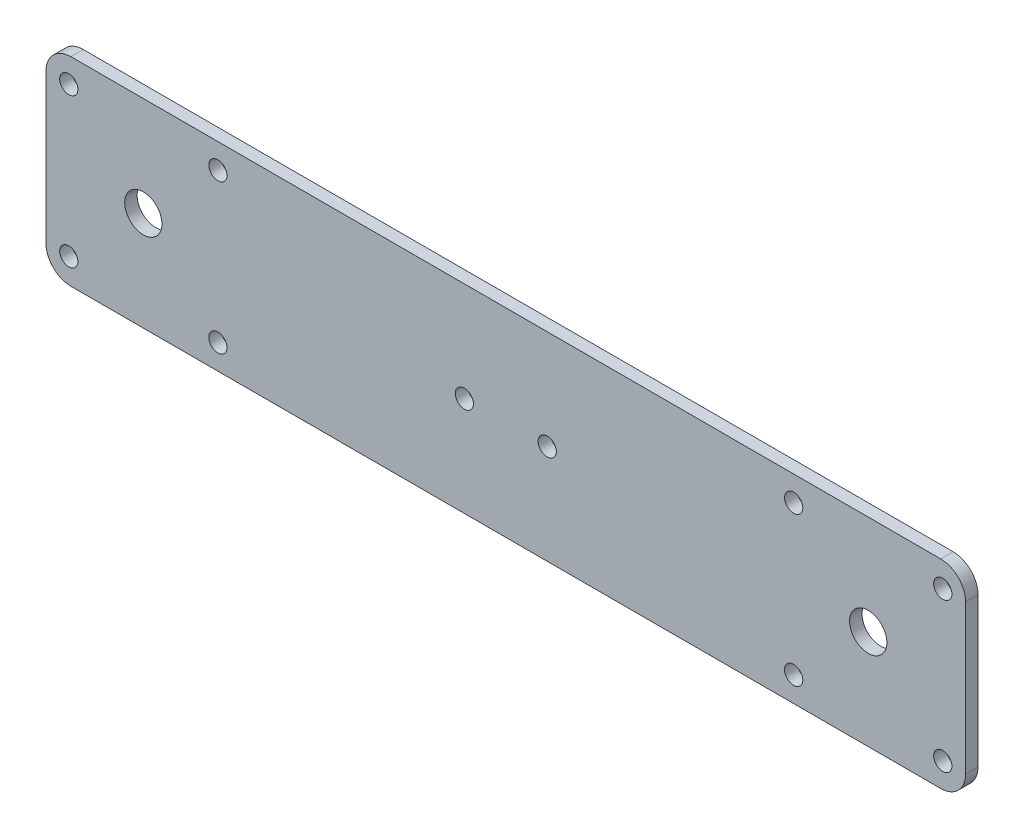
from build123d import *

# Parameters (mm, degrees)
ESQUISSE1_W             = 366
ESQUISSE1_H             = 166
ESQUISSE1_R             = 2.2
ESQUISSE1_R_2           = 4.5
ESQUISSE1_R_3           = 6.5
BOSS_EXTRU_1_DEPTH      = 3
ESQUISSE2_OUTSIDE_W     = 448.38
ESQUISSE2_OUTSIDE_H     = 248.38
ESQUISSE2_OUTSIDE_W_2   = 222
ESQUISSE2_OUTSIDE_H_2   = 48
ENL_V_MAT_EXTRU_1_DEPTH = 4
CONG_1_R                = 6


with BuildPart() as part:
    # Esquisse1 → Boss.-Extru.1 (new body)
    with BuildSketch(Plane.XY):
        with Locations((183, 83)):
            Rectangle(ESQUISSE1_W, ESQUISSE1_H)
        with Locations((13, 153)):
            Circle(ESQUISSE1_R, mode=Mode.SUBTRACT)
        with Locations((13, 13)):
            Circle(ESQUISSE1_R, mode=Mode.SUBTRACT)
        with Locations((13, 83)):
            Circle(ESQUISSE1_R, mode=Mode.SUBTRACT)
        with Locations((173, 153)):
            Circle(ESQUISSE1_R, mode=Mode.SUBTRACT)
        with Locations((193, 83)):
            Circle(ESQUISSE1_R, mode=Mode.SUBTRACT)
        with Locations((173, 83)):
            Circle(ESQUISSE1_R, mode=Mode.SUBTRACT)
        with Locations((193, 153)):
            Circle(ESQUISSE1_R, mode=Mode.SUBTRACT)
        with Locations((353, 83)):
            Circle(ESQUISSE1_R, mode=Mode.SUBTRACT)
        with Locations((353, 13)):
            Circle(ESQUISSE1_R, mode=Mode.SUBTRACT)
        with Locations((353, 153)):
            Circle(ESQUISSE1_R, mode=Mode.SUBTRACT)
        with Locations((193, 13)):
            Circle(ESQUISSE1_R, mode=Mode.SUBTRACT)
        with Locations((173, 13)):
            Circle(ESQUISSE1_R, mode=Mode.SUBTRACT)
        with Locations((270.5, 83)):
            Circle(ESQUISSE1_R_2, mode=Mode.SUBTRACT)
        with Locations((95.5, 83)):
            Circle(ESQUISSE1_R_2, mode=Mode.SUBTRACT)
        with Locations((77.5, 101)):
            Circle(ESQUISSE1_R, mode=Mode.SUBTRACT)
        with Locations((113.5, 101)):
            Circle(ESQUISSE1_R, mode=Mode.SUBTRACT)
        with Locations((77.5, 65)):
            Circle(ESQUISSE1_R, mode=Mode.SUBTRACT)
        with Locations((113.5, 65)):
            Circle(ESQUISSE1_R, mode=Mode.SUBTRACT)
        with Locations((288.5, 65)):
            Circle(ESQUISSE1_R, mode=Mode.SUBTRACT)
        with Locations((252.5, 65)):
            Circle(ESQUISSE1_R, mode=Mode.SUBTRACT)
        with Locations((252.5, 101)):
            Circle(ESQUISSE1_R, mode=Mode.SUBTRACT)
        with Locations((288.5, 101)):
            Circle(ESQUISSE1_R, mode=Mode.SUBTRACT)
        with Locations((37, 49)):
            Circle(ESQUISSE1_R_3, mode=Mode.SUBTRACT)
        with Locations((61, 49)):
            Circle(ESQUISSE1_R_3, mode=Mode.SUBTRACT)
        with Locations((85, 49)):
            Circle(ESQUISSE1_R, mode=Mode.SUBTRACT)
        with Locations((13, 49)):
            Circle(ESQUISSE1_R, mode=Mode.SUBTRACT)
    extrude(amount=BOSS_EXTRU_1_DEPTH)

    # Esquisse2 outside → Enlèv. mat.-Extru.1 (cut, through all)
    with BuildSketch(Plane.XY.offset(3)):
        with Locations((183, 83)):
            Rectangle(ESQUISSE2_OUTSIDE_W, ESQUISSE2_OUTSIDE_H)
        with Locations((183, 83)):
            Rectangle(ESQUISSE2_OUTSIDE_W_2, ESQUISSE2_OUTSIDE_H_2, mode=Mode.SUBTRACT)
    extrude(amount=-ENL_V_MAT_EXTRU_1_DEPTH, mode=Mode.SUBTRACT)

    # Congé1
    cong_1_edges = [part.edges().sort_by_distance(p)[0] for p in [
        (72, 107, 1.5),
        (294, 107, 1.5),
        (294, 59, 1.5),
        (72, 59, 1.5),
    ]]
    fillet(cong_1_edges, radius=CONG_1_R)


solid = part.part
